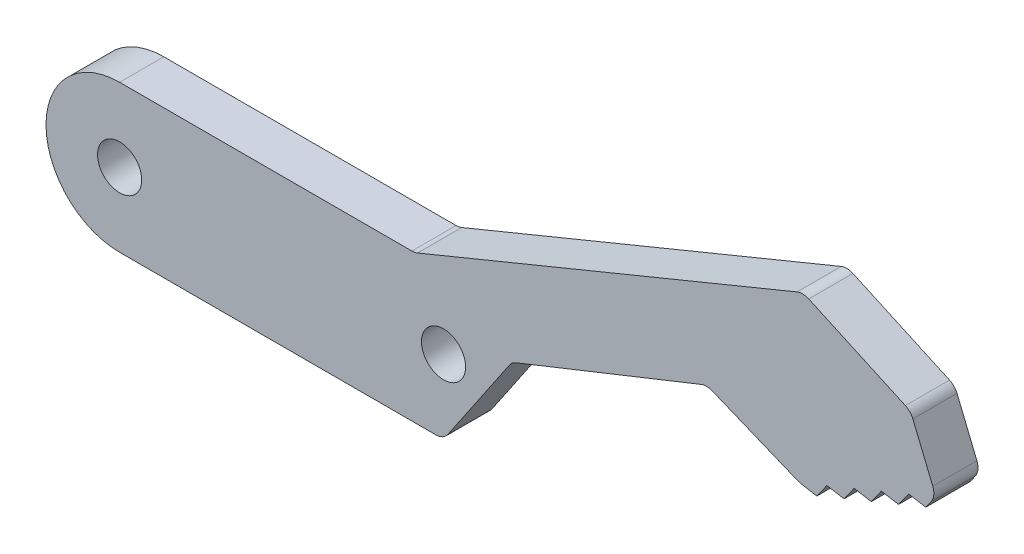
from build123d import *

# Parameters (mm, degrees)
SKETCH1_R           = 1.5
BOSS_EXTRUDE1_DEPTH = 3
FILLET1_R           = 1


with BuildPart() as part:
    # Sketch1 → Boss-Extrude1 (new body)
    with BuildSketch(Plane.XY):
        with BuildLine():
            Line((20.05, 5), (0, 5))
            ThreePointArc((0, 5), (-5, 0), (0, -5))
            Line((0, -5), (22, -5))
            Line((22, -5), (26.644435765, 1.851814361))
            ThreePointArc((26.644435765, 1.851814361), (24.805434743, 4.138784351), (22, 5))
            Line((22, 5), (20.05, 5))
        make_face()
        Circle(SKETCH1_R, mode=Mode.SUBTRACT)
        with Locations((22, 0)):
            Circle(SKETCH1_R, mode=Mode.SUBTRACT)
        with BuildLine():
            Line((46.409029503, 15.837507263), (20.05, 5))
            Line((20.05, 5), (22, 5))
            ThreePointArc((22, 5), (24.805434743, 4.138784351), (26.644435765, 1.851814361))
            Line((26.644435765, 1.851814361), (39.871788822, 7.125781662))
            Line((39.871788822, 7.125781662), (46.188488025, 4.540007042))
            Line((46.188488025, 4.540007042), (47.352932204, 4.337597171))
            Line((47.352932204, 4.337597171), (48.038244482, 5.300533868))
            Line((48.038244482, 5.300533868), (49.20268866, 5.098123997))
            Line((49.20268866, 5.098123997), (49.888000938, 6.061060693))
            Line((49.888000938, 6.061060693), (51.052445116, 5.858650822))
            Line((51.052445116, 5.858650822), (51.737757394, 6.821587519))
            Line((51.737757394, 6.821587519), (52.902201573, 6.619177648))
            Line((52.902201573, 6.619177648), (53.587513851, 7.582114344))
            Line((53.587513851, 7.582114344), (54.751958029, 7.379704473))
            Line((54.751958029, 7.379704473), (55.437270307, 8.34264117))
            Line((55.437270307, 8.34264117), (53.72608495, 12.504593197))
            Line((53.72608495, 12.504593197), (46.409029503, 15.837507263))
        make_face()
    extrude(amount=BOSS_EXTRUDE1_DEPTH)

    # Fillet1
    fillet1_edges = [part.edges().sort_by_distance(p)[0] for p in [
        (22, -5, 1.5),
        (20.05, 5, 1.5),
        (46.409029503, 15.837507263, 1.5),
        (53.72608495, 12.504593197, 1.5),
        (55.437270307, 8.34264117, 1.5),
        (46.188488025, 4.540007042, 1.5),
        (39.871788822, 7.125781662, 1.5),
        (26.644435765, 1.851814361, 1.5),
    ]]
    fillet(fillet1_edges, radius=FILLET1_R)


solid = part.part
